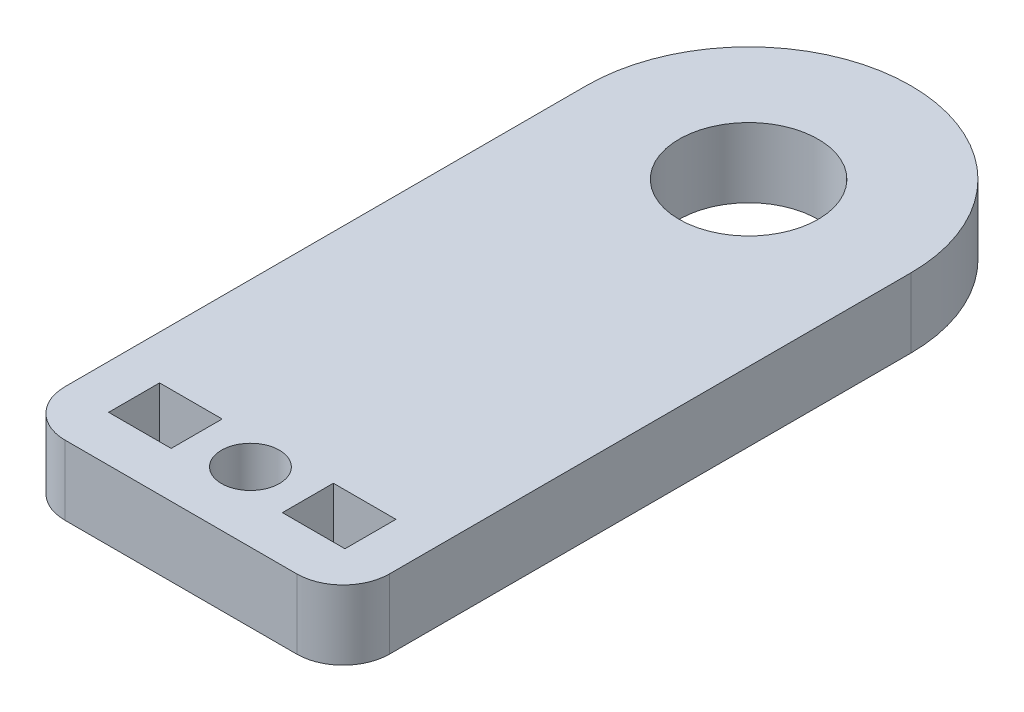
from build123d import *

# Parameters (mm, degrees)
SKETCH_1_R      = 7
SKETCH_1_R_2    = 3
EXTRUDE_2_DEPTH = 3
SKETCH_1_4_W    = 2.7
SKETCH_1_4_H    = 2.2
SKETCH_1_4_R    = 1.25
EXTRUDE_3_DEPTH = 3
FILLET_2_R      = 2


with BuildPart() as part:
    # 草图1 → 凸台-拉伸2 (new body)
    with BuildSketch(Plane(origin=(0, 0, 0), x_dir=(1, 0, 0), z_dir=(0, 1, 0))):
        with Locations((0, 12.25)):
            Circle(SKETCH_1_R)
        with Locations((0, 12.25)):
            Circle(SKETCH_1_R_2, mode=Mode.SUBTRACT)
    extrude(amount=EXTRUDE_2_DEPTH)

    # 草图1<4> → 凸台-拉伸3 (add)
    with BuildSketch(Plane(origin=(0, 0, 0), x_dir=(1, 0, 0), z_dir=(0, 1, 0))):
        with BuildLine():
            ThreePointArc((7, 12.25), (4.949747468, 7.300252532), (0, 5.25))
            ThreePointArc((0, 5.25), (-4.949747468, 7.300252532), (-7, 12.25))
            Line((-7, 12.25), (-7, -12.25))
            Line((-7, -12.25), (7, -12.25))
            Line((7, -12.25), (7, 12.25))
        make_face()
        with Locations((-3.75, -9.170716156)):
            Rectangle(SKETCH_1_4_W, SKETCH_1_4_H, mode=Mode.SUBTRACT)
        with Locations((0, -9.25)):
            Circle(SKETCH_1_4_R, mode=Mode.SUBTRACT)
        with Locations((3.75, -9.170716156)):
            Rectangle(SKETCH_1_4_W, SKETCH_1_4_H, mode=Mode.SUBTRACT)
    extrude(amount=EXTRUDE_3_DEPTH)

    # 圆角2
    fillet_2_edges = [part.edges().sort_by_distance(p)[0] for p in [
        (7, 1.5, 12.25),
        (-7, 1.5, 12.25),
    ]]
    fillet(fillet_2_edges, radius=FILLET_2_R)


solid = part.part
